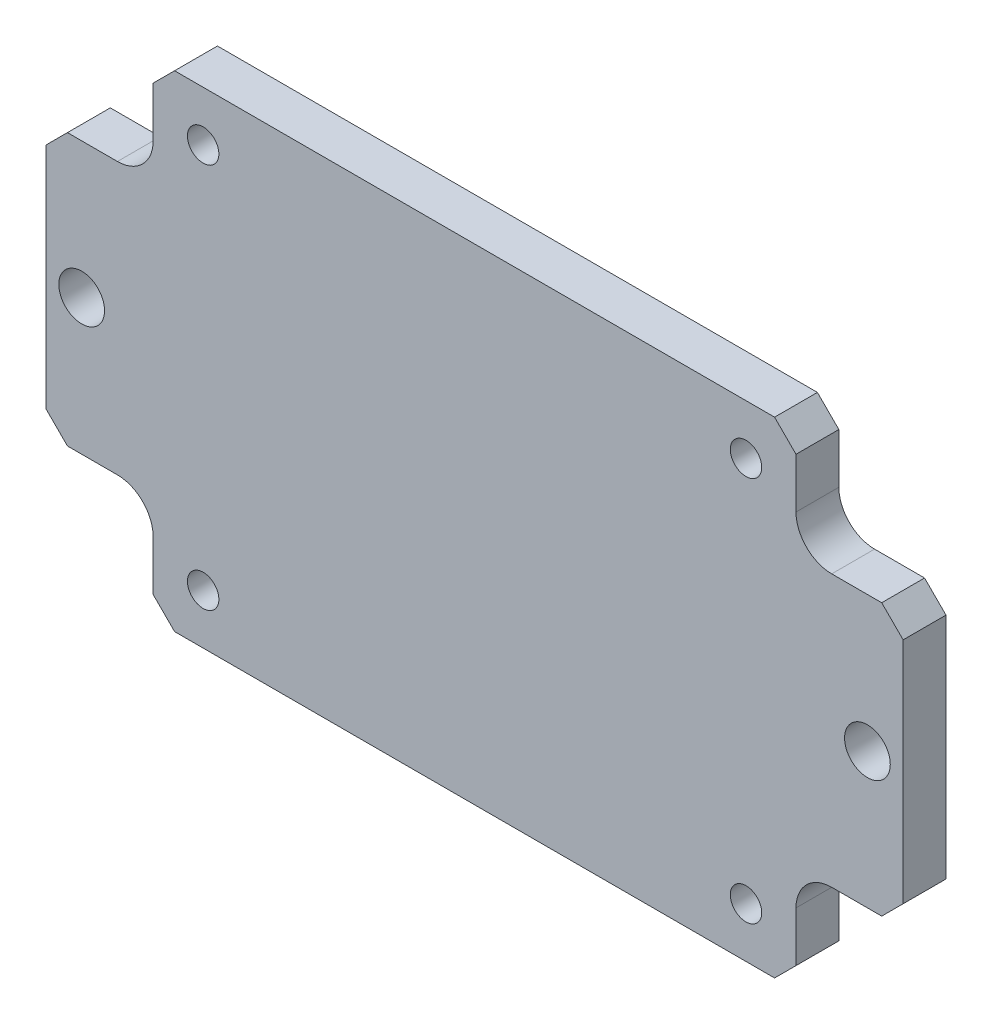
from build123d import *

# Parameters (mm, degrees)
SKETCH1_W                = 60
SKETCH1_H                = 34
BOSS_EXTRUDE1_DEPTH      = 3
CUT_EXTRUDE1_REACH       = 5
M2_CLEARANCE_HOLE1_D     = 2.2
M2_CLEARANCE_HOLE1_DEPTH = 3
M3_CLEARANCE_HOLE1_D     = 3.2
M3_CLEARANCE_HOLE1_DEPTH = 3
CUT_EXTRUDE2_DEPTH       = 0.2
FILLET2_R                = 4


with BuildPart() as part:
    # Sketch1 → Boss-Extrude1 (new body)
    with BuildSketch(Plane.XY):
        Rectangle(SKETCH1_W, SKETCH1_H)
    extrude(amount=BOSS_EXTRUDE1_DEPTH)

    # Sketch2 → Cut-Extrude1 (cut, up to next)
    with BuildSketch(Plane.XY.offset(3), mode=Mode.PRIVATE) as cut_extrude1_sk1:
        with BuildLine():
            Line((21, 17), (22.5, 15.5))
            Line((22.5, 15.5), (22.5, 12))
            ThreePointArc((22.5, 12), (23.232233047, 10.232233047), (25, 9.5))
            Line((25, 9.5), (28.5, 9.5))
            Line((28.5, 9.5), (30, 8))
            Line((30, 8), (30, 17))
            Line((30, 17), (21, 17))
        make_face()
    cut_extrude1_tool1 = extrude(cut_extrude1_sk1.sketch, amount=-CUT_EXTRUDE1_REACH, mode=Mode.PRIVATE) & part.part
    add(cut_extrude1_tool1.solids().sort_by_distance((26.30521, 13.30521, 3))[0], mode=Mode.SUBTRACT)
    # Sketch2 → Cut-Extrude1 (cut, up to next)
    with BuildSketch(Plane.XY.offset(3), mode=Mode.PRIVATE) as cut_extrude1_sk2:
        with BuildLine():
            Line((-30, 17), (-21, 17))
            Line((-21, 17), (-22.5, 15.5))
            Line((-22.5, 15.5), (-22.5, 12))
            ThreePointArc((-22.5, 12), (-23.232233047, 10.232233047), (-25, 9.5))
            Line((-25, 9.5), (-28.5, 9.5))
            Line((-28.5, 9.5), (-30, 8))
            Line((-30, 8), (-30, 17))
        make_face()
    cut_extrude1_tool2 = extrude(cut_extrude1_sk2.sketch, amount=-CUT_EXTRUDE1_REACH, mode=Mode.PRIVATE) & part.part
    add(cut_extrude1_tool2.solids().sort_by_distance((-26.30521, 13.30521, 3))[0], mode=Mode.SUBTRACT)
    # Sketch2 → Cut-Extrude1 (cut, up to next)
    with BuildSketch(Plane.XY.offset(3), mode=Mode.PRIVATE) as cut_extrude1_sk3:
        with BuildLine():
            Line((30, -8), (30, -17))
            Line((30, -17), (21, -17))
            Line((21, -17), (22.5, -15.5))
            Line((22.5, -15.5), (22.5, -12))
            ThreePointArc((22.5, -12), (23.232233047, -10.232233047), (25, -9.5))
            Line((25, -9.5), (28.5, -9.5))
            Line((28.5, -9.5), (30, -8))
        make_face()
    cut_extrude1_tool3 = extrude(cut_extrude1_sk3.sketch, amount=-CUT_EXTRUDE1_REACH, mode=Mode.PRIVATE) & part.part
    add(cut_extrude1_tool3.solids().sort_by_distance((26.30521, -13.30521, 3))[0], mode=Mode.SUBTRACT)
    # Sketch2 → Cut-Extrude1 (cut, up to next)
    with BuildSketch(Plane.XY.offset(3), mode=Mode.PRIVATE) as cut_extrude1_sk4:
        with BuildLine():
            Line((-22.5, -15.5), (-22.5, -12))
            ThreePointArc((-22.5, -12), (-23.232233047, -10.232233047), (-25, -9.5))
            Line((-25, -9.5), (-28.5, -9.5))
            Line((-28.5, -9.5), (-30, -8))
            Line((-30, -8), (-30, -17))
            Line((-30, -17), (-21, -17))
            Line((-21, -17), (-22.5, -15.5))
        make_face()
    cut_extrude1_tool4 = extrude(cut_extrude1_sk4.sketch, amount=-CUT_EXTRUDE1_REACH, mode=Mode.PRIVATE) & part.part
    add(cut_extrude1_tool4.solids().sort_by_distance((-26.30521, -13.30521, 3))[0], mode=Mode.SUBTRACT)

    # M2 Clearance Hole1
    with Locations(Plane.XY.offset(3)):
        with Locations((19, 13.5), (-19, -13.5), (-19, 13.5), (19, -13.5)):
            Hole(M2_CLEARANCE_HOLE1_D / 2, depth=M2_CLEARANCE_HOLE1_DEPTH)

    # M3 Clearance Hole1
    with Locations(Plane.XY.offset(3)):
        with Locations((-27.5, 0), (27.5, 0)):
            Hole(M3_CLEARANCE_HOLE1_D / 2, depth=M3_CLEARANCE_HOLE1_DEPTH)

    # Sketch7 → Cut-Extrude2 (cut)
    with BuildSketch(Plane(origin=(0, 0, 0), x_dir=(-1, 0, 0), z_dir=(0, 0, -1))):
        with BuildLine():
            Line((-7.5, -13), (7.5, -13))
            ThreePointArc((7.5, -13), (17.577822185, -10.323688824), (25, -3))
            Line((25, -3), (25, 3))
            ThreePointArc((25, 3), (17.577822185, 10.323688824), (7.5, 13))
            Line((7.5, 13), (-7.5, 13))
            ThreePointArc((-7.5, 13), (-17.577822185, 10.323688824), (-25, 3))
            Line((-25, 3), (-25, -3))
            ThreePointArc((-25, -3), (-17.577822185, -10.323688824), (-7.5, -13))
        make_face()
    extrude(amount=-CUT_EXTRUDE2_DEPTH, mode=Mode.SUBTRACT)

    # Fillet2
    fillet2_edges = [part.edges().sort_by_distance(p)[0] for p in [
        (25, -3, 0.1),
        (25, 3, 0.1),
        (-25, 3, 0.1),
        (-25, -3, 0.1),
    ]]
    fillet(fillet2_edges, radius=FILLET2_R)


solid = part.part
